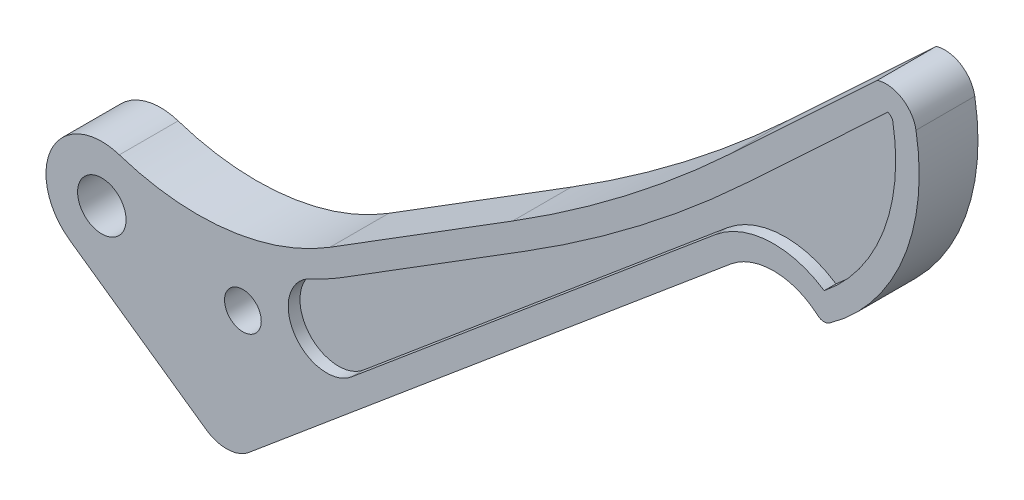
from build123d import *

# Parameters (mm, degrees)
SKETCH1_R           = 6.5484375
SKETCH1_R_2         = 4.9609375
BOSS_EXTRUDE1_DEPTH = 15.875
CUT_EXTRUDE1_DEPTH  = 3.175


with BuildPart() as part:
    # Sketch1 → Boss-Extrude1 (new body)
    with BuildSketch(Plane.XY):
        with BuildLine():
            Line((39.309837535, -38.13576648), (169.802643178, 71.308446723))
            ThreePointArc((169.802643178, 71.308446723), (181.638701023, 75.538599133), (193.375235205, 71.039685917))
            ThreePointArc((193.375235205, 71.039685917), (194.91888163, 70.411561678), (196.519579076, 70.875406513))
            ThreePointArc((196.519579076, 70.875406513), (216.426062494, 95.878722868), (219.876867623, 127.651759468))
            ThreePointArc((219.876867623, 127.651759468), (216.10638338, 133.218163447), (209.442132072, 134.106509769))
            Line((209.442132072, 134.106509769), (169.802643178, 97.116806131))
            ThreePointArc((169.802643178, 97.116806131), (141.448926781, 73.105263596), (110.917160699, 51.932198905))
            Line((110.917160699, 51.932198905), (61.60231529, 21.139969158))
            ThreePointArc((61.60231529, 21.139969158), (33.929413541, 11.389122801), (4.735454932, 14.318504397))
            ThreePointArc((4.735454932, 14.318504397), (-13.47453995, 6.773542256), (-8.666712343, -12.34229309))
            Line((-8.666712343, -12.34229309), (28.215623228, -38.240932071))
            ThreePointArc((28.215623228, -38.240932071), (33.77962274, -39.970371676), (39.309837535, -38.13576648))
        make_face()
        Circle(SKETCH1_R, mode=Mode.SUBTRACT)
        with Locations((38.1, -5.431682667)):
            Circle(SKETCH1_R_2, mode=Mode.SUBTRACT)
    extrude(amount=BOSS_EXTRUDE1_DEPTH)

    # Sketch2 → Cut-Extrude1 (cut)
    with BuildSketch(Plane(origin=(0, 0, 0), x_dir=(-1, 0, 0), z_dir=(0, 0, -1))):
        with BuildLine():
            Line((-174.134916332, 92.474187331), (-212.247088608, 128.038671053))
            ThreePointArc((-212.247088608, 128.038671053), (-213.153727633, 127.498423524), (-213.622663407, 126.552928441))
            ThreePointArc((-213.622663407, 126.552928441), (-211.065734224, 99.589440169), (-195.076715953, 77.728084278))
            ThreePointArc((-195.076715953, 77.728084278), (-180.13970514, 81.855576515), (-165.722085208, 76.173788093))
            Line((-165.722085208, 76.173788093), (-67.427567629, -6.265746298))
            ThreePointArc((-67.427567629, -6.265746298), (-58.337399342, -8.416558755), (-51.185588969, -2.40750208))
            ThreePointArc((-51.185588969, -2.40750208), (-51.037402279, 5.455937622), (-56.434934077, 11.176277972))
            ThreePointArc((-56.434934077, 11.176277972), (-60.775393958, 13.324892332), (-64.965487459, 15.753729935))
            Line((-64.965487459, 15.753729935), (-114.280332868, 46.545959683))
            ThreePointArc((-114.280332868, 46.545959683), (-145.314571941, 68.067477625), (-174.134916332, 92.474187331))
        make_face()
    cut_extrude1 = extrude(amount=-CUT_EXTRUDE1_DEPTH, mode=Mode.SUBTRACT)

    # Mirror1: Cut-Extrude1 across plane
    add(cut_extrude1.mirror(Plane(origin=(0, 0, 7.9375), x_dir=(1, 0, 0), z_dir=(0, 0, -1))), mode=Mode.SUBTRACT)


solid = part.part
